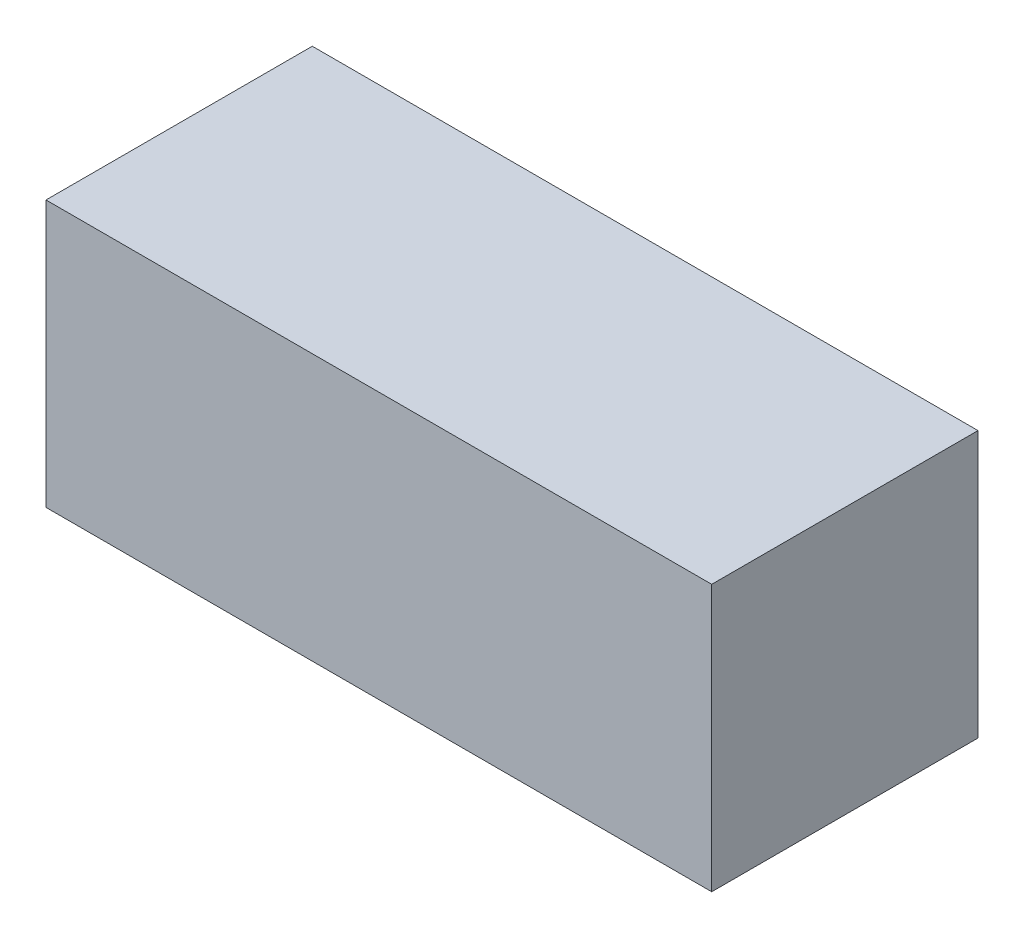
from build123d import *

# Parameters (mm, degrees)
SKETCH1_W           = 101.6
SKETCH1_H           = 101.6
BOSS_EXTRUDE1_DEPTH = 254


with BuildPart() as part:
    # Sketch1 → Boss-Extrude1 (new body)
    with BuildSketch(Plane(origin=(0, 0, 0), x_dir=(0, 0, -1), z_dir=(1, 0, 0))):
        Rectangle(SKETCH1_W, SKETCH1_H)
    extrude(amount=BOSS_EXTRUDE1_DEPTH)


solid = part.part
